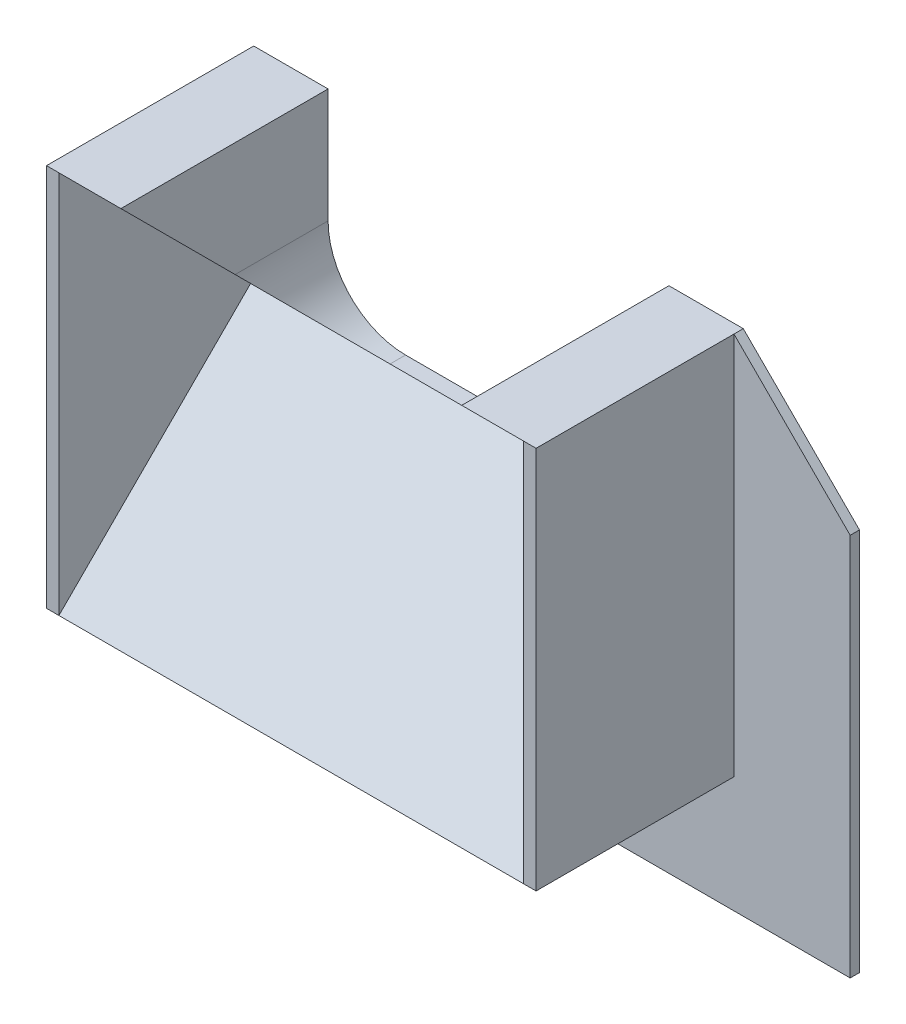
from build123d import *

# Parameters (mm, degrees)
BOSS_EXTRUDE1_DEPTH = 60
SKETCH2_W           = 44
SKETCH2_H           = 24.748737342
CUT_EXTRUDE1_DEPTH  = 27.748737342
FILLET1_R           = 10
SKETCH5_W           = 26.748737342
SKETCH5_H           = 49.497474684
BOSS_EXTRUDE3_DEPTH = 1.6
BOSS_EXTRUDE4_DEPTH = 1.2


with BuildPart() as part:
    # Sketch1 → Boss-Extrude1 (new body)
    with BuildSketch(Plane(origin=(0, 0, 0), x_dir=(0, 0, -1), z_dir=(1, 0, 0))):
        Polygon((-24.748737342, 24.748737342), (0, 0), (-24.748737342, -24.748737342), (2, -24.748737342), (2, 24.748737342), align=None)
    extrude(amount=BOSS_EXTRUDE1_DEPTH)

    # Sketch2 → Cut-Extrude1 (cut, through all)
    with BuildSketch(Plane(origin=(0, 0, -2), x_dir=(-1, 0, 0), z_dir=(0, 0, -1))):
        with Locations((-30, 12.374368671)):
            Rectangle(SKETCH2_W, SKETCH2_H)
    extrude(amount=-CUT_EXTRUDE1_DEPTH, mode=Mode.SUBTRACT)

    # Fillet1
    fillet1_edges = [part.edges().sort_by_distance(p)[0] for p in [
        (8, 0, -1),
        (52, 0, -1),
    ]]
    fillet(fillet1_edges, radius=FILLET1_R)

    # Sketch5 → Boss-Extrude3 (add)
    with BuildSketch(Plane.ZY):
        with Locations((11.374368671, 0)):
            Rectangle(SKETCH5_W, SKETCH5_H)
    boss_extrude3 = extrude(amount=BOSS_EXTRUDE3_DEPTH)

    # Mirror1: Boss-Extrude3 across plane
    add(boss_extrude3.mirror(Plane.ZY.offset(-30)))

    # Sketch6 → Boss-Extrude4 (add)
    with BuildSketch(Plane(origin=(0, 0, -2), x_dir=(-1, 0, 0), z_dir=(0, 0, -1))):
        Polygon((1.6, 24.748737342), (16.6, 9.748737342), (16.6, -39.748737342), (-76.6, -39.748737342), (-76.6, 9.748737342), (-61.6, 24.748737342), (-61.6, -24.748737342), (1.6, -24.748737342), align=None)
    extrude(amount=-BOSS_EXTRUDE4_DEPTH)


solid = part.part
